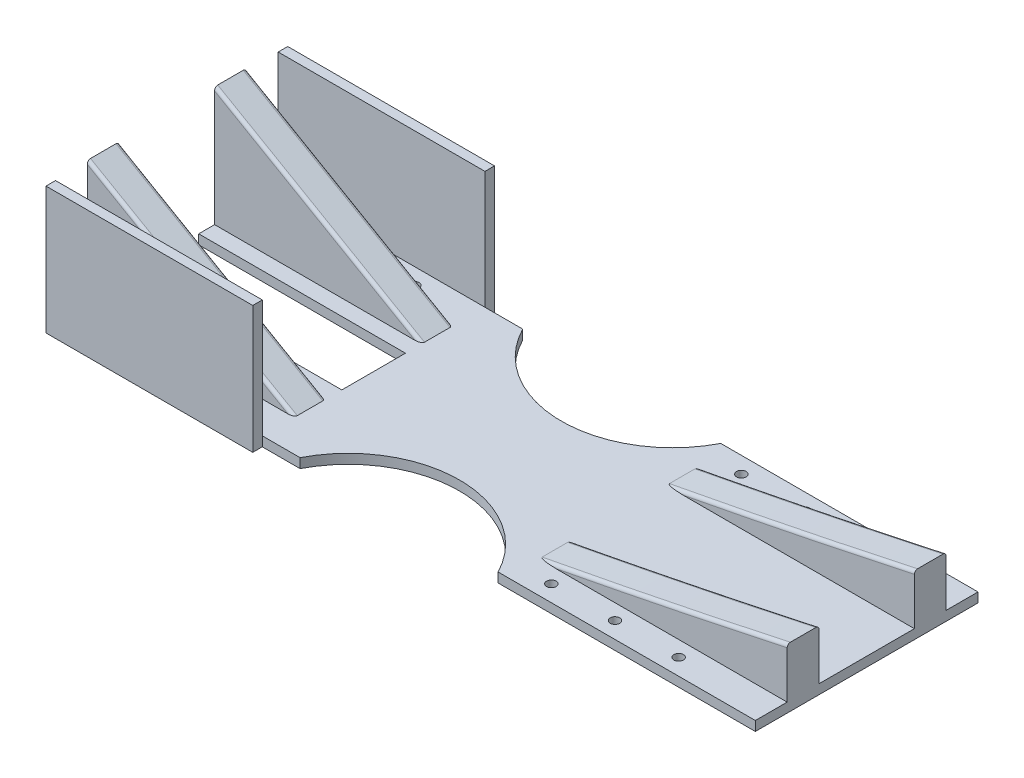
from build123d import *

# Parameters (mm, degrees)
SKETCH_1_W           = 220
SKETCH_1_H           = 70
EXTRUDE_1_DEPTH      = 3
EXTRUDE_2_DEPTH      = 25
EXTRUDE_2_DEPTH_BACK = 25
SKETCH_6_W           = 30
SKETCH_6_H           = 37.527767497
CUT_EXTRUDE_4_DEPTH  = 221.0000001
SKETCH_7_R           = 35
CUT_EXTRUDE_5_DEPTH  = 4
SKETCH_8_W           = 3
SKETCH_8_H           = 40
EXTRUDE_3_DEPTH      = 65
SKETCH_9_R           = 1.5
CUT_EXTRUDE_6_DEPTH  = 4
FILLET_5_R           = 1
SKETCH_10_W          = 65
SKETCH_10_H          = 20
CUT_EXTRUDE_7_DEPTH  = 4.0000001


with BuildPart() as part:
    # 草图1 → 凸台-拉伸1 (new body)
    with BuildSketch(Plane(origin=(0, 0, 0), x_dir=(1, 0, 0), z_dir=(0, 1, 0))):
        with Locations((27.295373665, 0)):
            Rectangle(SKETCH_1_W, SKETCH_1_H)
    extrude(amount=EXTRUDE_1_DEPTH)

    # 草图2 → 凸台-拉伸2 (add, two sides)
    with BuildSketch(Plane.XY) as extrude_2_sk:
        Polygon((-82.704626335, 40.527767497), (-82.704626335, 3), (-17.704626335, 3), align=None)
        with BuildLine():
            Line((137.295373665, 3), (137.295373665, 18.810437945))
            add(Edge.make_bspline(
                [(59.295373665, 3), (98.406140267, 10.357107668), (137.295373665, 18.810437945)],
                knots=[0, 0, 0, 1, 1, 1], degree=2))
            Line((59.295373665, 3), (137.295373665, 3))
        make_face()
    extrude(amount=EXTRUDE_2_DEPTH)
    extrude(extrude_2_sk.sketch, amount=-EXTRUDE_2_DEPTH_BACK)

    # 草图6 → 切除-拉伸4 (cut, through all)
    with BuildSketch(Plane.ZY.offset(82.704626335)):
        with Locations((0, 21.763883748)):
            Rectangle(SKETCH_6_W, SKETCH_6_H)
    extrude(amount=-CUT_EXTRUDE_4_DEPTH, mode=Mode.SUBTRACT)

    # 草图7 → 切除-拉伸5 (cut, through all)
    with BuildSketch(Plane(origin=(0, 3, 0), x_dir=(1, 0, 0), z_dir=(0, 1, 0))):
        with Locations((25.295373665, 51)):
            Circle(SKETCH_7_R)
        with Locations((25.295373665, -51)):
            Circle(SKETCH_7_R)
    extrude(amount=-CUT_EXTRUDE_5_DEPTH, mode=Mode.SUBTRACT)

    # 草图8 → 凸台-拉伸3 (add)
    with BuildSketch(Plane.ZY.offset(82.704626335)):
        with Locations((36.5, 20)):
            Rectangle(SKETCH_8_W, SKETCH_8_H)
        with Locations((-36.5, 20)):
            Rectangle(SKETCH_8_W, SKETCH_8_H)
    extrude(amount=-EXTRUDE_3_DEPTH)

    # 草图9 → 切除-拉伸6 (cut, through all)
    with BuildSketch(Plane(origin=(0, 3, 0), x_dir=(1, 0, 0), z_dir=(0, 1, 0))):
        with Locations((-74.766784803, 29.860059225)):
            Circle(SKETCH_9_R)
        with Locations((-54.766784803, 29.860059225)):
            Circle(SKETCH_9_R)
        with Locations((-34.766784803, 29.860059225)):
            Circle(SKETCH_9_R)
        with Locations((-34.766784803, -29.860059225)):
            Circle(SKETCH_9_R)
        with Locations((-54.766784803, -29.860059225)):
            Circle(SKETCH_9_R)
        with Locations((-74.766784803, -29.860059225)):
            Circle(SKETCH_9_R)
        with Locations((68.031562246, 29.860059225)):
            Circle(SKETCH_9_R)
        with Locations((88.031562246, 29.860059225)):
            Circle(SKETCH_9_R)
        with Locations((108.031562246, 29.860059225)):
            Circle(SKETCH_9_R)
        with Locations((108.031562246, -29.860059225)):
            Circle(SKETCH_9_R)
        with Locations((88.031562246, -29.860059225)):
            Circle(SKETCH_9_R)
        with Locations((68.031562246, -29.860059225)):
            Circle(SKETCH_9_R)
    extrude(amount=-CUT_EXTRUDE_6_DEPTH, mode=Mode.SUBTRACT)

    # 圆角5
    fillet_5_edges = [part.edges().sort_by_distance(p)[0] for p in [
        (98.35091757, 10.631195874, -25),
        (98.35091757, 10.631195874, 25),
        (-50.204626335, 21.763883749, -25),
        (-50.204626335, 21.763883749, 25),
        (-50.204626335, 21.763883749, -15),
        (-50.204626335, 21.763883749, 15),
        (98.35091757, 10.631195874, 15),
        (98.35091757, 10.631195874, -15),
    ]]
    fillet(fillet_5_edges, radius=FILLET_5_R)

    # 草图10 → 切除-拉伸7 (cut, through all)
    with BuildSketch(Plane(origin=(0, 3, 0), x_dir=(1, 0, 0), z_dir=(0, 1, 0))):
        with Locations((-50.204626335, 0)):
            Rectangle(SKETCH_10_W, SKETCH_10_H)
    extrude(amount=-CUT_EXTRUDE_7_DEPTH, mode=Mode.SUBTRACT)


solid = part.part
